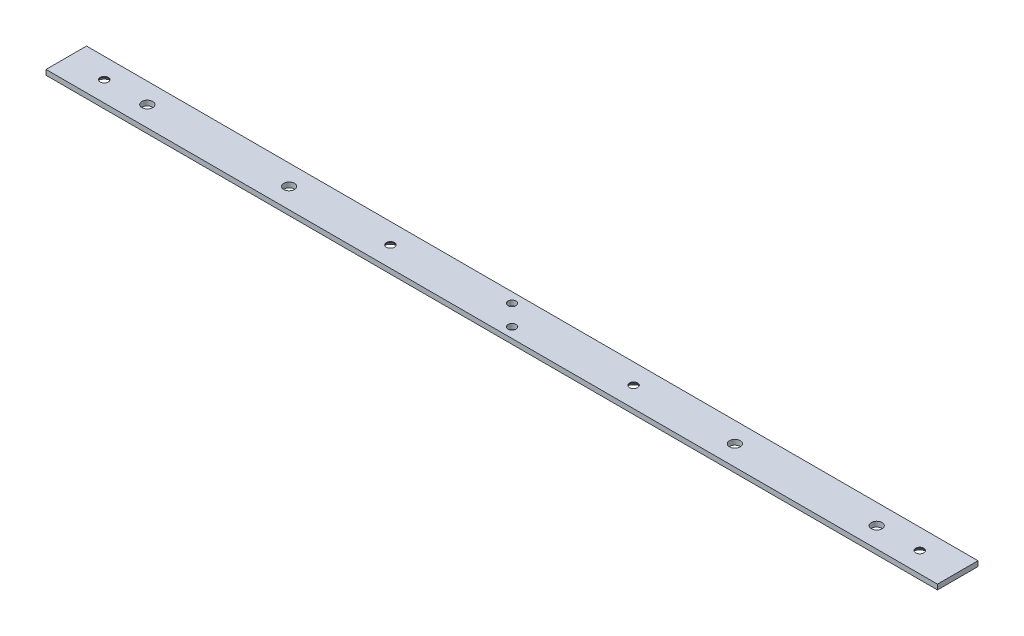
from build123d import *

# Parameters (mm, degrees)
SKETCH1_W                                    = 25.4
SKETCH1_H                                    = 3.175
BOSS_EXTRUDE1_DEPTH                          = 279.4
F_1_4_CLEARANCE_HOLE1_D                      = 6.7564
F_10_CLEARANCE_HOLE1_D                       = 5.1054
CSK_FOR_10_FLAT_HEAD_MACHINE_SCREW1_AT_COUNT = 2
CSK_FOR_10_FLAT_HEAD_MACHINE_SCREW1_AT_PITCH = 50.8
CSK_FOR_10_FLAT_HEAD_MACHINE_SCREW1_2_COUNT  = 2
CSK_FOR_10_FLAT_HEAD_MACHINE_SCREW1_2_PITCH  = 186.441720536
CSK_FOR_10_FLAT_HEAD_MACHINE_SCREW1_3_COUNT  = 2
CSK_FOR_10_FLAT_HEAD_MACHINE_SCREW1_3_PITCH  = 179.3875
CSK_FOR_10_FLAT_HEAD_MACHINE_SCREW1_4_COUNT  = 2
CSK_FOR_10_FLAT_HEAD_MACHINE_SCREW1_4_PITCH  = 331.7875
CSK_FOR_10_FLAT_HEAD_MACHINE_SCREW1_5_COUNT  = 2
CSK_FOR_10_FLAT_HEAD_MACHINE_SCREW1_5_PITCH  = 152.4
CSK_FOR_10_FLAT_HEAD_MACHINE_SCREW1_6_COUNT  = 2
CSK_FOR_10_FLAT_HEAD_MACHINE_SCREW1_6_PITCH  = 160.643705137
CSK_FOR_10_FLAT_HEAD_MACHINE_SCREW1_7_COUNT  = 2
CSK_FOR_10_FLAT_HEAD_MACHINE_SCREW1_7_PITCH  = 335.653966394


with BuildPart() as part:
    # Sketch1 → Boss-Extrude1 (new body, symmetric)
    with BuildSketch(Plane(origin=(0, 0, 0), x_dir=(0, 0, -1), z_dir=(1, 0, 0))):
        Rectangle(SKETCH1_W, SKETCH1_H)
    extrude(amount=BOSS_EXTRUDE1_DEPTH, both=True)

    # 1/4 Clearance Hole1 (through all)
    with Locations(Plane(origin=(0, 1.5875, 0), x_dir=(1, 0, 0), z_dir=(0, 1, 0))):
        with Locations((-139.7, 0), (-228.6, 0)):
            f_1_4_clearance_hole1 = Hole(F_1_4_CLEARANCE_HOLE1_D / 2)

    # Mirror1: 1/4 Clearance Hole1 across plane
    add(f_1_4_clearance_hole1.mirror(Plane(origin=(0, 0, 0), x_dir=(0, 0, 1), z_dir=(1, 0, 0))), mode=Mode.SUBTRACT)

    # #10 Clearance Hole1 (through all)
    with Locations(Plane(origin=(0, 1.5875, 0), x_dir=(1, 0, 0), z_dir=(0, 1, 0))):
        with Locations((6.35, -6.35), (-6.35, 6.35)):
            Hole(F_10_CLEARANCE_HOLE1_D / 2)

    # Sketch7 → CSK for #10 Flat Head Machine Screw1 (revolve, cut)
    with BuildSketch(Plane(origin=(-76.2, -1.5875, 0), x_dir=(0, 0, -1), z_dir=(1, 0, 0))):
        Polygon((0, 0), (0, 3.175), (2.5527, 3.175), (2.5527, 2.688180894), (4.8895, 0), align=None)
    csk_for_10_flat_head_machine_screw1 = revolve(axis=Axis((-76.2, -7.9375, 0), (0, 1, 0)), mode=Mode.SUBTRACT)

    # CSK for #10 Flat Head Machine Screw1 at: CSK for #10 Flat Head Machine Screw1 ×2
    with Locations(*[(0, 0, -i * CSK_FOR_10_FLAT_HEAD_MACHINE_SCREW1_AT_PITCH) for i in range(1, CSK_FOR_10_FLAT_HEAD_MACHINE_SCREW1_AT_COUNT)]):
        add(csk_for_10_flat_head_machine_screw1, mode=Mode.SUBTRACT)

    # CSK for _10 Flat Head Machine Screw1 2: CSK for #10 Flat Head Machine Screw1 ×2
    with Locations(*[Vector(-0.962163938, 0, -0.272471204) * (i * CSK_FOR_10_FLAT_HEAD_MACHINE_SCREW1_2_PITCH) for i in range(1, CSK_FOR_10_FLAT_HEAD_MACHINE_SCREW1_2_COUNT)]):
        add(csk_for_10_flat_head_machine_screw1, mode=Mode.SUBTRACT)

    # CSK for _10 Flat Head Machine Screw1 3: CSK for #10 Flat Head Machine Screw1 ×2
    with Locations(*[(-i * CSK_FOR_10_FLAT_HEAD_MACHINE_SCREW1_3_PITCH, 0, 0) for i in range(1, CSK_FOR_10_FLAT_HEAD_MACHINE_SCREW1_3_COUNT)]):
        add(csk_for_10_flat_head_machine_screw1, mode=Mode.SUBTRACT)

    # CSK for _10 Flat Head Machine Screw1 4: CSK for #10 Flat Head Machine Screw1 ×2
    with Locations(*[(i * CSK_FOR_10_FLAT_HEAD_MACHINE_SCREW1_4_PITCH, 0, 0) for i in range(1, CSK_FOR_10_FLAT_HEAD_MACHINE_SCREW1_4_COUNT)]):
        add(csk_for_10_flat_head_machine_screw1, mode=Mode.SUBTRACT)

    # CSK for _10 Flat Head Machine Screw1 5: CSK for #10 Flat Head Machine Screw1 ×2
    with Locations(*[(i * CSK_FOR_10_FLAT_HEAD_MACHINE_SCREW1_5_PITCH, 0, 0) for i in range(1, CSK_FOR_10_FLAT_HEAD_MACHINE_SCREW1_5_COUNT)]):
        add(csk_for_10_flat_head_machine_screw1, mode=Mode.SUBTRACT)

    # CSK for _10 Flat Head Machine Screw1 6: CSK for #10 Flat Head Machine Screw1 ×2
    with Locations(*[Vector(0.948683298, 0, -0.316227766) * (i * CSK_FOR_10_FLAT_HEAD_MACHINE_SCREW1_6_PITCH) for i in range(1, CSK_FOR_10_FLAT_HEAD_MACHINE_SCREW1_6_COUNT)]):
        add(csk_for_10_flat_head_machine_screw1, mode=Mode.SUBTRACT)

    # CSK for _10 Flat Head Machine Screw1 7: CSK for #10 Flat Head Machine Screw1 ×2
    with Locations(*[Vector(0.988480796, 0, -0.151346342) * (i * CSK_FOR_10_FLAT_HEAD_MACHINE_SCREW1_7_PITCH) for i in range(1, CSK_FOR_10_FLAT_HEAD_MACHINE_SCREW1_7_COUNT)]):
        add(csk_for_10_flat_head_machine_screw1, mode=Mode.SUBTRACT)


solid = part.part
